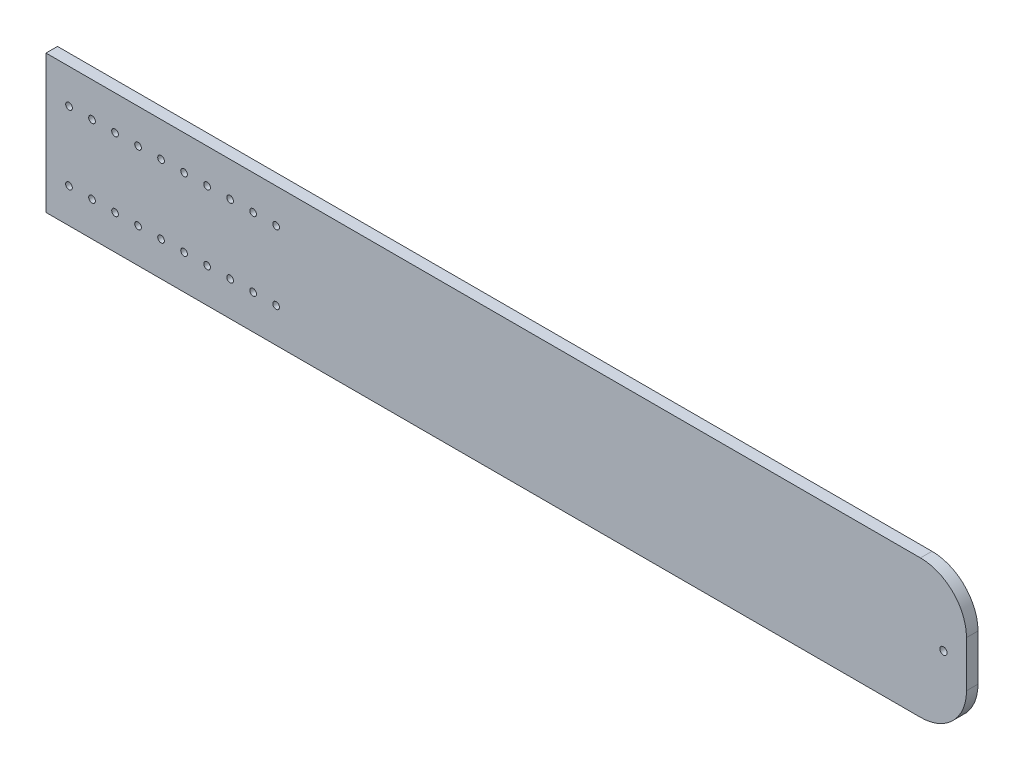
from build123d import *

# Parameters (mm, degrees)
SKETCH1_W             = 508
SKETCH1_H             = 76.2
BASIC_PLANK_DEPTH     = 6.35
SKETCH2_R             = 1.8415
PLACEMENT_HOLES_DEPTH = 7.35
FILLET1_R             = 25.4
SKETCH3_R             = 2.0066
WHEEL_HOLE_DEPTH      = 7.35


with BuildPart() as part:
    # Sketch1 → basic_plank (new body)
    with BuildSketch(Plane.XY):
        with Locations((254, 38.1)):
            Rectangle(SKETCH1_W, SKETCH1_H)
    extrude(amount=BASIC_PLANK_DEPTH)

    # Sketch2 → placement holes (cut, through all)
    with BuildSketch(Plane.XY.offset(6.35)):
        with Locations((12.7, 57.15)):
            Circle(SKETCH2_R)
        with Locations((25.4, 57.15)):
            Circle(SKETCH2_R)
        with Locations((38.1, 57.15)):
            Circle(SKETCH2_R)
        with Locations((50.8, 57.15)):
            Circle(SKETCH2_R)
        with Locations((63.5, 57.15)):
            Circle(SKETCH2_R)
        with Locations((76.2, 57.15)):
            Circle(SKETCH2_R)
        with Locations((88.9, 57.15)):
            Circle(SKETCH2_R)
        with Locations((101.6, 57.15)):
            Circle(SKETCH2_R)
        with Locations((114.3, 57.15)):
            Circle(SKETCH2_R)
        with Locations((127, 57.15)):
            Circle(SKETCH2_R)
        with Locations((12.7, 19.05)):
            Circle(SKETCH2_R)
        with Locations((25.4, 19.05)):
            Circle(SKETCH2_R)
        with Locations((38.1, 19.05)):
            Circle(SKETCH2_R)
        with Locations((50.8, 19.05)):
            Circle(SKETCH2_R)
        with Locations((63.5, 19.05)):
            Circle(SKETCH2_R)
        with Locations((76.2, 19.05)):
            Circle(SKETCH2_R)
        with Locations((88.9, 19.05)):
            Circle(SKETCH2_R)
        with Locations((101.6, 19.05)):
            Circle(SKETCH2_R)
        with Locations((114.3, 19.05)):
            Circle(SKETCH2_R)
        with Locations((127, 19.05)):
            Circle(SKETCH2_R)
    extrude(amount=-PLACEMENT_HOLES_DEPTH, mode=Mode.SUBTRACT)

    # Fillet1
    fillet1_edges = [part.edges().sort_by_distance(p)[0] for p in [
        (508, 76.2, 3.175),
        (508, 0, 3.175),
    ]]
    fillet(fillet1_edges, radius=FILLET1_R)

    # Sketch3 → wheel_hole (cut, through all)
    with BuildSketch(Plane.XY.offset(6.35)):
        with Locations((495.3, 38.1)):
            Circle(SKETCH3_R)
    extrude(amount=-WHEEL_HOLE_DEPTH, mode=Mode.SUBTRACT)


solid = part.part
